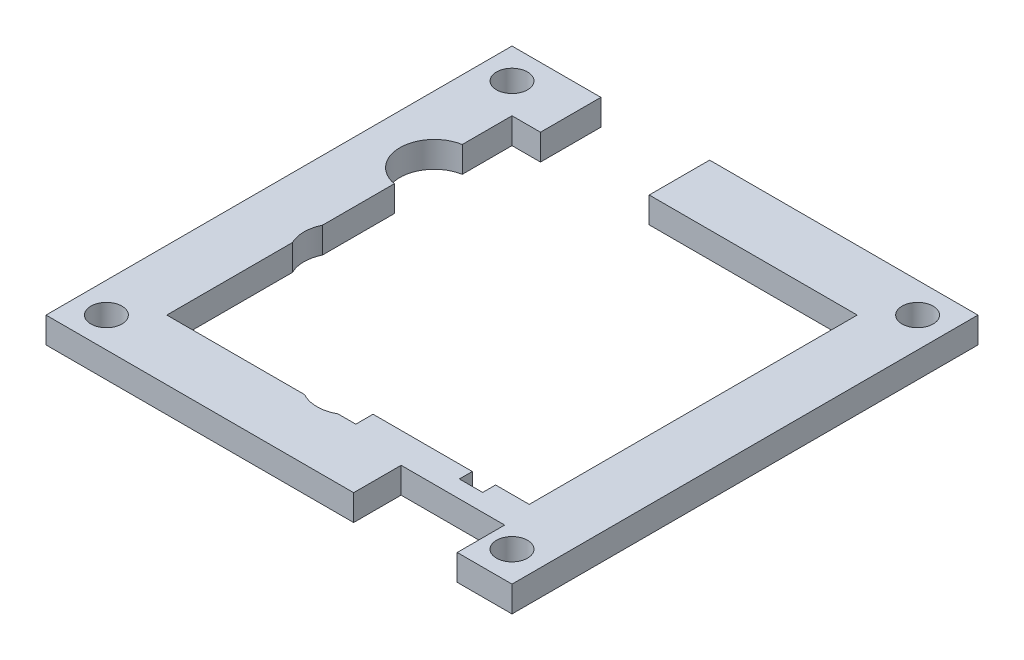
from build123d import *

# Parameters (mm, degrees)
SKETCH_3_R      = 1.8
SKETCH_3_W      = 0.8
SKETCH_3_H      = 1.5
SKETCH_3_W_2    = 1
EXTRUDE_2_DEPTH = 3


with BuildPart() as part:
    # 草图3 → 凸台-拉伸2 (new body)
    with BuildSketch(Plane(origin=(0, 0, 0), x_dir=(1, 0, 0), z_dir=(0, 1, 0))):
        with BuildLine():
            Line((8.65, -27), (8.65, -21.5))
            Line((8.65, -21.5), (8.65, -20))
            Line((8.65, -20), (1.9, -20))
            Line((1.9, -20), (-0.163508327, -20))
            ThreePointArc((-0.163508327, -20), (-2.1, -20.5), (-4.036491673, -20))
            Line((-4.036491673, -20), (-20, -20))
            Line((-20, -20), (-20, -5.443559577))
            ThreePointArc((-20, -5.443559577), (-20.4, -3.7), (-20, -1.956440423))
            Line((-20, -1.956440423), (-20, 6.361726266))
            ThreePointArc((-20, 6.361726266), (-23.3, 10.3), (-20, 14.238273734))
            Line((-20, 14.238273734), (-20, 20))
            Line((-20, 20), (-16.7, 20))
            Line((-16.7, 20), (-16.7, 27))
            Line((-16.7, 27), (-27, 27))
            Line((-27, 27), (-27, -27))
            Line((-27, -27), (8.65, -27))
        make_face()
        with Locations((-23.5, -23.5)):
            Circle(SKETCH_3_R, mode=Mode.SUBTRACT)
        with Locations((-23.5, 23.5)):
            Circle(SKETCH_3_R, mode=Mode.SUBTRACT)
        Polygon((20, -18), (20, -20), (20.65, -20), (20.65, -21.5), (20.65, -27), (27, -27), (27, 27), (-4.1, 27), (-4.1, 20), (20, 20), align=None)
        with Locations((23.5, -23.5)):
            Circle(SKETCH_3_R, mode=Mode.SUBTRACT)
        with Locations((23.5, 23.5)):
            Circle(SKETCH_3_R, mode=Mode.SUBTRACT)
        Polygon((12.4, -20), (12.4, -19.5), (12.4, -18), (1.9, -18), (1.9, -20), (8.65, -20), align=None)
        Polygon((20, -20), (16.9, -20), (16.9, -19.5), (16.1, -19.5), (13.4, -19.5), (12.4, -19.5), (12.4, -20), (8.65, -20), (8.65, -21.5), (20.65, -21.5), (20.65, -20), align=None)
        Polygon((16.9, -19.5), (16.9, -20), (20, -20), (20, -18), (16.9, -18), align=None)
        with Locations((16.5, -18.75)):
            Rectangle(SKETCH_3_W, SKETCH_3_H)
        with Locations((12.9, -18.75)):
            Rectangle(SKETCH_3_W_2, SKETCH_3_H)
    extrude(amount=EXTRUDE_2_DEPTH)


solid = part.part
